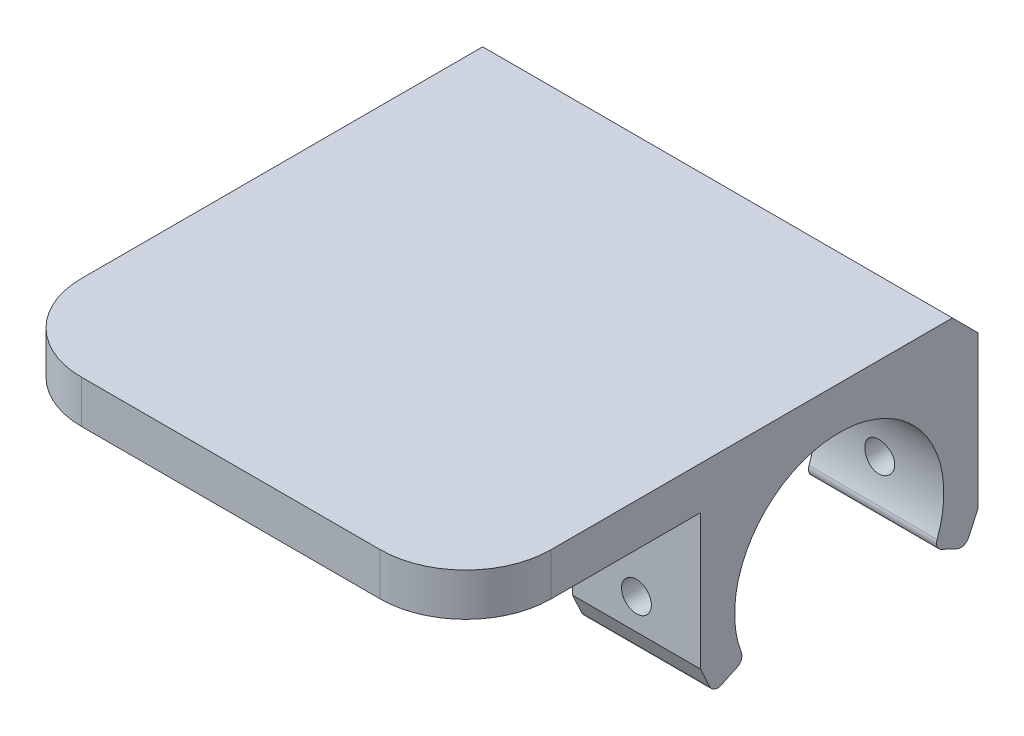
from build123d import *

# Parameters (mm, degrees)
SKETCH_1_R               = 12.25
EXTRUDE_1_DEPTH          = 27.5
CUT_EXTRUDE_2_DEPTH      = 1
CUT_EXTRUDE_2_DEPTH_BACK = 56
EXTRUDE_2_DEPTH          = 55
FILLET_1_R               = 1
SKETCH_5_R               = 1.75
CUT_EXTRUDE_3_DEPTH      = 61
SKETCH_2_W               = 25
SKETCH_2_H               = 30
CUT_EXTRUDE_1_DEPTH      = 33.5000001
FILLET_2_R               = 10
CHAMFER_1_SIZE           = 3


with BuildPart() as part:
    # ｽｹｯﾁ1 → ﾎﾞｽ - 押し出し1 (new body, symmetric)
    with BuildSketch(Plane(origin=(0, 0, 0), x_dir=(0, 0, -1), z_dir=(1, 0, 0))):
        with BuildLine():
            Line((16.25, 0), (16.25, 17.25))
            Line((16.25, 17.25), (-43.75, 17.25))
            Line((-43.75, 17.25), (-43.75, 12.25))
            Line((-43.75, 12.25), (-16.25, 12.25))
            Line((-16.25, 12.25), (-16.25, 0))
            ThreePointArc((-16.25, 0), (0, -16.25), (16.25, 0))
        make_face()
        Circle(SKETCH_1_R, mode=Mode.SUBTRACT)
    extrude(amount=EXTRUDE_1_DEPTH, both=True)

    # ｽｹｯﾁ3 → ｶｯﾄ - 押し出し2 (cut, two sides)
    with BuildSketch(Plane(origin=(27.5, 0, 0), x_dir=(0, 0, -1), z_dir=(1, 0, 0))) as cut_extrude_2_sk:
        Polygon((-152.616304173, -71.166151395), (-17.557784777, -8.187329502), (0, 0), (20.401420048, -9.513338406), (155.459939444, -72.492160299), (154.177134941, -370.530575754), (-153.899108676, -369.20456685), align=None)
    extrude(amount=CUT_EXTRUDE_2_DEPTH, mode=Mode.SUBTRACT)
    extrude(cut_extrude_2_sk.sketch, amount=-CUT_EXTRUDE_2_DEPTH_BACK, mode=Mode.SUBTRACT)

    # ｽｹｯﾁ4 → ﾎﾞｽ - 押し出し2 (add)
    with BuildSketch(Plane.ZY.offset(27.5)):
        with BuildLine():
            Line((16.25, 0), (16.25, -3.602538268))
            Line((16.25, -3.602538268), (14.727501539, -6.867546753))
            ThreePointArc((14.727501539, -6.867546753), (15.864810116, -3.517143726), (16.25, 0))
        make_face()
        with BuildLine():
            Line((-16.25, 0), (-16.25, -3.602538268))
            Line((-16.25, -3.602538268), (-14.727501539, -6.867546753))
            ThreePointArc((-14.727501539, -6.867546753), (-15.864810116, -3.517143726), (-16.25, 0))
        make_face()
    extrude(amount=-EXTRUDE_2_DEPTH)

    # ﾌｨﾚｯﾄ1
    fillet_1_edges = [part.edges().sort_by_distance(p)[0] for p in [
        (0, -5.177073706, -11.102270391),
        (0, -5.177073706, 11.102270391),
        (0, -6.867546753, 14.727501539),
        (0, -6.867546753, -14.727501539),
    ]]
    fillet(fillet_1_edges, radius=FILLET_1_R)

    # ｽｹｯﾁ5 → ｶｯﾄ - 押し出し3 (cut, through all)
    with BuildSketch(Plane(origin=(0, 0, -16.25), x_dir=(-1, 0, 0), z_dir=(0, 0, -1))):
        with Locations((20, 0)):
            Circle(SKETCH_5_R)
        with Locations((-20, 0)):
            Circle(SKETCH_5_R)
    extrude(amount=-CUT_EXTRUDE_3_DEPTH, mode=Mode.SUBTRACT)

    # ｽｹｯﾁ2 → ｶｯﾄ - 押し出し1 (cut, through all)
    with BuildSketch(Plane.XY.offset(16.25)):
        with Locations((0, -2.75)):
            Rectangle(SKETCH_2_W, SKETCH_2_H)
    extrude(amount=-CUT_EXTRUDE_1_DEPTH, mode=Mode.SUBTRACT)

    # ﾌｨﾚｯﾄ2
    fillet_2_edges = [part.edges().sort_by_distance(p)[0] for p in [
        (27.5, 14.75, 43.75),
        (-27.5, 14.75, 43.75),
    ]]
    fillet(fillet_2_edges, radius=FILLET_2_R)

    # 面取り1
    chamfer_1_edges = [part.edges().sort_by_distance(p)[0] for p in [
        (0, 17.25, -16.25),
    ]]
    chamfer(chamfer_1_edges, length=CHAMFER_1_SIZE)


solid = part.part
